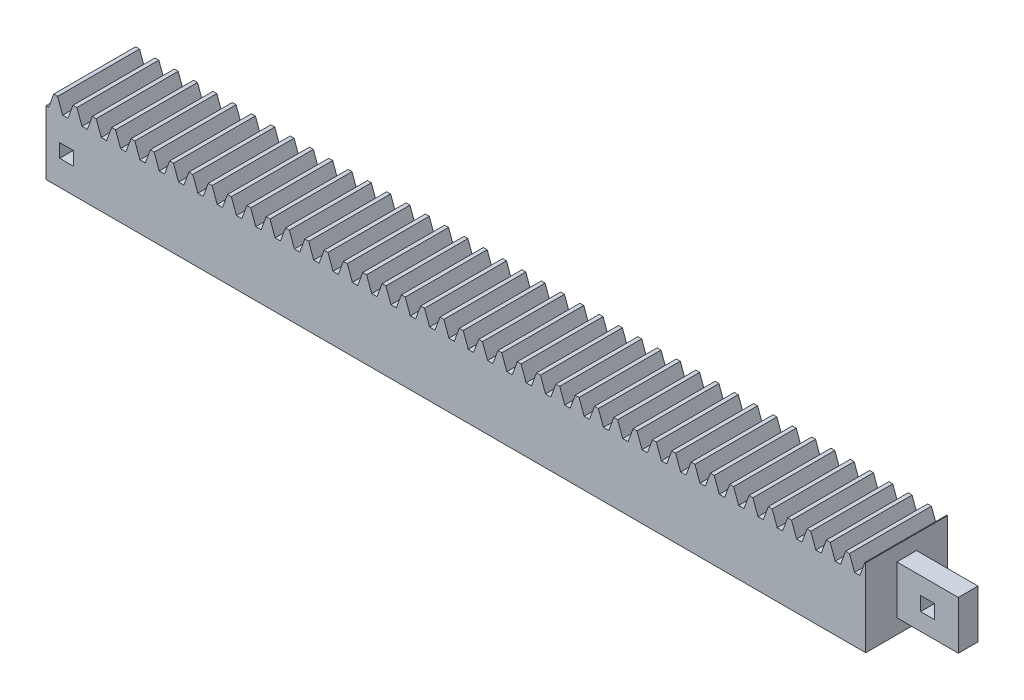
from build123d import *

# Parameters (mm, degrees)
BLANKSKE_W          = 200
BLANKSKE_H          = 19
BLANK_DEPTH         = 20
TOOTHCUTSIM_DEPTH   = 202.893536301
TEETHCUTS_COUNT     = 43
TEETHCUTS_PITCH     = 4.712388975
SKETCH1_W           = 4.8
SKETCH1_H           = 19
BOSS_EXTRUDE1_DEPTH = 15
SKETCH2_W           = 15
SKETCH2_H           = 3.6
SKETCH2_W_2         = 3.4
SKETCH2_H_2         = 3.4
CUT_EXTRUDE1_DEPTH  = 4.8
SKETCH3_W           = 7
SKETCH3_H           = 7
CUT_EXTRUDE3_DEPTH  = 10
SKETCH4_W           = 3.3
SKETCH4_H           = 3.3
CUT_EXTRUDE4_DEPTH  = 25


with BuildPart() as part:
    # BlankSke → Blank (new body)
    with BuildSketch(Plane.XY):
        with Locations((100, 9.5)):
            Rectangle(BLANKSKE_W, BLANKSKE_H)
    extrude(amount=-BLANK_DEPTH)

    # TooCutSkeSim → ToothCutSim (cut, through all)
    with BuildSketch(Plane.XY):
        Polygon((0.654653055, 15.625), (-0.654653055, 15.625), (-1.892297439, 19.0254), (1.892297439, 19.0254), align=None)
    toothcutsim = extrude(amount=-TOOTHCUTSIM_DEPTH, mode=Mode.SUBTRACT)

    # TeethCuts: ToothCutSim ×43
    with Locations(*[(i * TEETHCUTS_PITCH, 0, 0) for i in range(1, TEETHCUTS_COUNT)]):
        add(toothcutsim, mode=Mode.SUBTRACT)

    # Sketch1 → Boss-Extrude1 (add)
    with BuildSketch(Plane(origin=(200, 0, 0), x_dir=(0, 0, -1), z_dir=(1, 0, 0))):
        with Locations((10, 9.5)):
            Rectangle(SKETCH1_W, SKETCH1_H)
    extrude(amount=BOSS_EXTRUDE1_DEPTH)

    # Sketch2 → Cut-Extrude1 (cut)
    with BuildSketch(Plane(origin=(0, 0, -12.4), x_dir=(-1, 0, 0), z_dir=(0, 0, -1))):
        with Locations((-207.5, 17.2)):
            Rectangle(SKETCH2_W, SKETCH2_H)
        with Locations((-207.5, 1.8)):
            Rectangle(SKETCH2_W, SKETCH2_H)
        with Locations((-207.5, 9.5)):
            Rectangle(SKETCH2_W_2, SKETCH2_H_2)
    extrude(amount=-CUT_EXTRUDE1_DEPTH, mode=Mode.SUBTRACT)

    # Sketch3 → Cut-Extrude3 (cut)
    with BuildSketch(Plane.ZY):
        with Locations((-10, 7.8125)):
            Rectangle(SKETCH3_W, SKETCH3_H)
    extrude(amount=-CUT_EXTRUDE3_DEPTH, mode=Mode.SUBTRACT)

    # Sketch4 → Cut-Extrude4 (cut)
    with BuildSketch(Plane(origin=(0, 0, -20), x_dir=(-1, 0, 0), z_dir=(0, 0, -1))):
        with Locations((-5, 7.8125)):
            Rectangle(SKETCH4_W, SKETCH4_H)
    extrude(amount=-CUT_EXTRUDE4_DEPTH, mode=Mode.SUBTRACT)


solid = part.part
